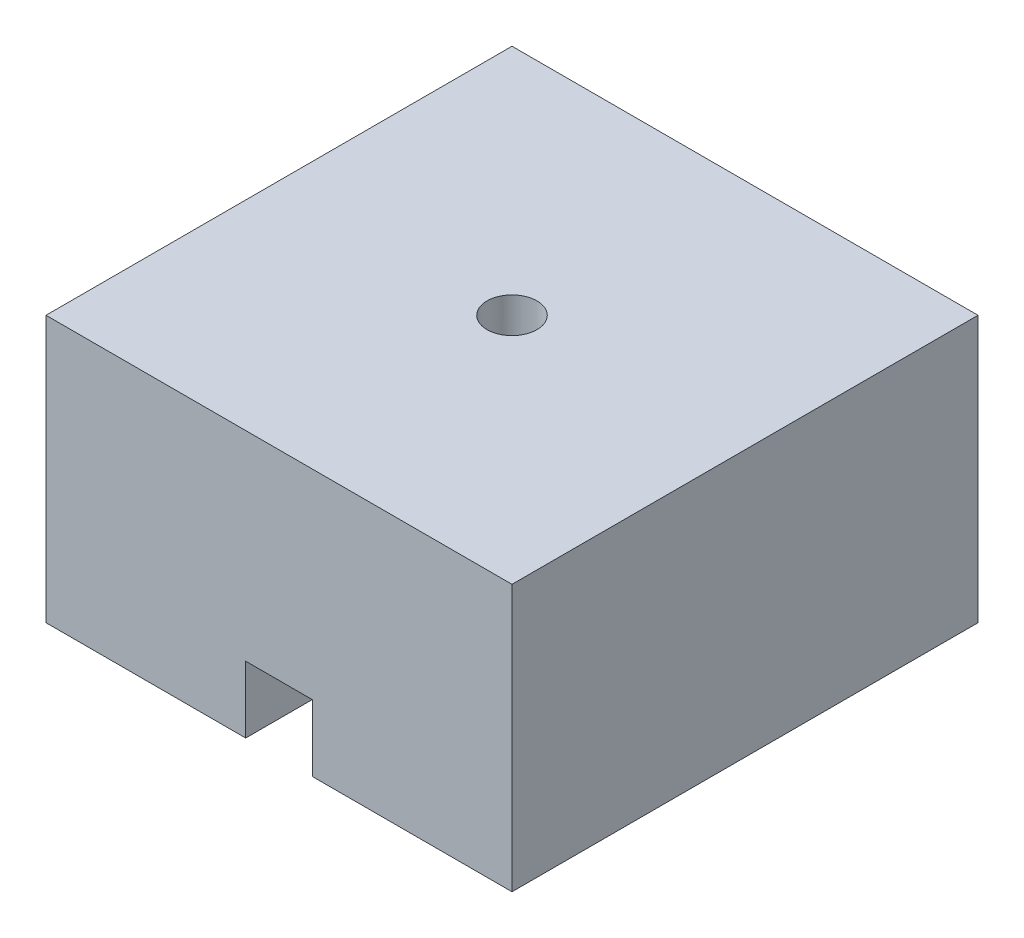
from build123d import *

# Parameters (mm, degrees)
SKETCH1_W           = 88.9
SKETCH1_H           = 88.9
BOSS_EXTRUDE1_DEPTH = 50.8
SHELL1_T            = -1.5875
SKETCH4_R           = 4.7625
CUT_EXTRUDE3_DEPTH  = 51.8
SKETCH5_W           = 15.875
SKETCH5_H           = 73.025
SKETCH5_W_2         = 12.7
SKETCH5_H_2         = 69.85
EXTRUDE_THIN1_DEPTH = 49.2125
SKETCH10_R          = 7.9375
SKETCH10_R_2        = 4.7625
BOSS_EXTRUDE5_DEPTH = 6.35
SKETCH14_W          = 15.875
SKETCH14_H          = 14.2875
BOSS_EXTRUDE7_DEPTH = 7.9375
CUT_EXTRUDE6_START  = -9.525
SKETCH15_W          = 12.7
SKETCH15_H          = 12.7
CUT_EXTRUDE6_DEPTH  = 9.525


with BuildPart() as part:
    # Sketch1 → Boss-Extrude1 (new body)
    with BuildSketch(Plane(origin=(0, 0, 0), x_dir=(1, 0, 0), z_dir=(0, 1, 0))):
        Rectangle(SKETCH1_W, SKETCH1_H)
    extrude(amount=BOSS_EXTRUDE1_DEPTH)

    # Shell1
    shell1_openings = [part.faces().sort_by_distance(p)[0] for p in [
        (0, 0, 0),
    ]]
    offset(amount=SHELL1_T, openings=shell1_openings, kind=Kind.INTERSECTION)

    # Sketch4 → Cut-Extrude3 (cut, through all)
    with BuildSketch(Plane(origin=(0, 50.8, 0), x_dir=(1, 0, 0), z_dir=(0, 1, 0))):
        Circle(SKETCH4_R)
    extrude(amount=-CUT_EXTRUDE3_DEPTH, mode=Mode.SUBTRACT)

    # Sketch5 → Extrude-Thin1 (add)
    with BuildSketch(Plane.XZ.offset(-49.2125)):
        Rectangle(SKETCH5_W, SKETCH5_H)
        Rectangle(SKETCH5_W_2, SKETCH5_H_2, mode=Mode.SUBTRACT)
    extrude(amount=EXTRUDE_THIN1_DEPTH)

    # Sketch10 → Boss-Extrude5 (add)
    with BuildSketch(Plane.XZ.offset(-49.2125)):
        Circle(SKETCH10_R)
        Circle(SKETCH10_R_2, mode=Mode.SUBTRACT)
    extrude(amount=BOSS_EXTRUDE5_DEPTH)

    # Sketch14 → Boss-Extrude7 (add)
    with BuildSketch(Plane.XY.offset(44.45)):
        with Locations((0, 7.14375)):
            Rectangle(SKETCH14_W, SKETCH14_H)
    extrude(amount=-BOSS_EXTRUDE7_DEPTH)

    # Sketch15 → Cut-Extrude6 (cut)
    with BuildSketch(Plane.XY.offset(44.45).offset(CUT_EXTRUDE6_START)):
        with Locations((0, 6.35)):
            Rectangle(SKETCH15_W, SKETCH15_H)
    extrude(amount=CUT_EXTRUDE6_DEPTH, mode=Mode.SUBTRACT)


solid = part.part
